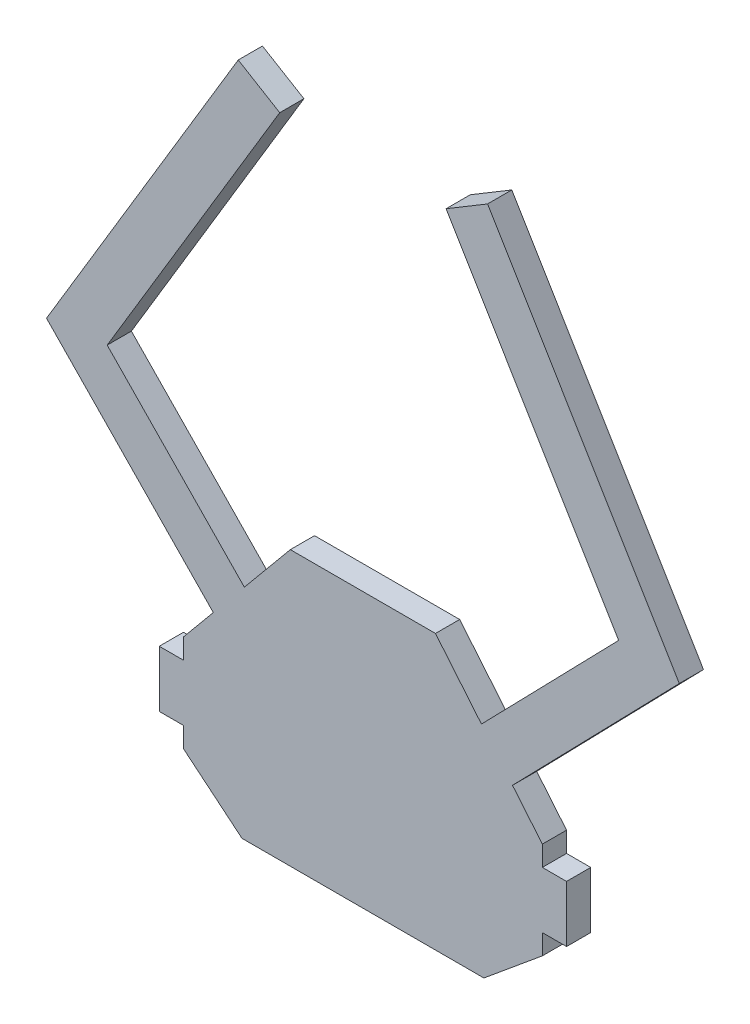
from build123d import *

# Parameters (mm, degrees)
CROQUIS1_W              = 44.5
CROQUIS1_H              = 12
CROQUIS1_W_2            = 3
CROQUIS1_H_2            = 7
SALIENTE_EXTRUIR1_DEPTH = 3
EXTRUIR_L_MINA1_DEPTH   = 3


with BuildPart() as part:
    # Croquis1 → Saliente-Extruir1 (new body)
    with BuildSketch(Plane.XY):
        Polygon((-15, -12), (15, -12), (22.25, -6), (-22.25, -6), align=None)
        Rectangle(CROQUIS1_W, CROQUIS1_H)
        Polygon((9, 22), (22.25, 6), (-22.25, 6), (-9, 22), align=None)
        with Locations((23.75, 0)):
            Rectangle(CROQUIS1_W_2, CROQUIS1_H_2)
        with Locations((-23.75, 0)):
            Rectangle(CROQUIS1_W_2, CROQUIS1_H_2)
    extrude(amount=SALIENTE_EXTRUIR1_DEPTH)

    # Croquis2 → Extruir-Lámina1 (add, through all)
    with BuildSketch(Plane.XY.offset(3)):
        Polygon((10.313415418, 68.264367666), (31.70862995, 32.607243184), (0, 0), (-31.70862995, 32.607243184), (-10.313415418, 68.264367666), (-15.458313145, 71.35144191), (-39.229366975, 31.734759205), (0, -8.606356476), (39.229366975, 31.734759205), (15.458313145, 71.35144191), align=None)
    extrude(amount=-EXTRUIR_L_MINA1_DEPTH)


solid = part.part
